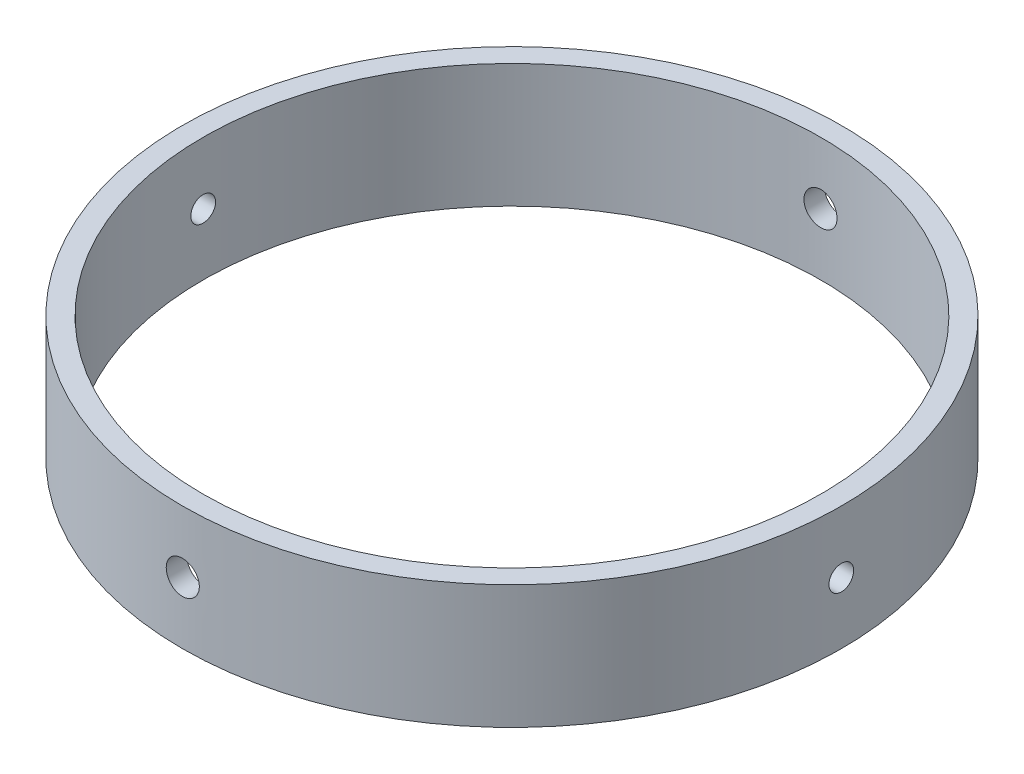
from build123d import *

# Parameters (mm, degrees)
SKETCH1_R                       = 50.8
SKETCH1_R_2                     = 47.625
BOSS_EXTRUDE1_DEPTH             = 19.05
SKETCH5_W                       = 2.5527
SKETCH5_H                       = 82.55
TAP_DRILL_FOR_1_4_20_TAP2_D     = 5.1054
TAP_DRILL_FOR_1_4_20_TAP2_DEPTH = 82.55
SKETCH10_R                      = 1.905
CUT_EXTRUDE3_DEPTH              = 83.5500001
CUT_EXTRUDE3_DEPTH_BACK         = 20.0500001


with BuildPart() as part:
    # Sketch1 → Boss-Extrude1 (new body)
    with BuildSketch(Plane(origin=(0, 0, 0), x_dir=(1, 0, 0), z_dir=(0, 1, 0))):
        Circle(SKETCH1_R)
        Circle(SKETCH1_R_2, mode=Mode.SUBTRACT)
    extrude(amount=BOSS_EXTRUDE1_DEPTH)

    # Sketch5 → Tap Drill for 1/4-20 Tap1 (revolve, cut)
    with BuildSketch(Plane(origin=(0, 9.525, 31.75), x_dir=(0, -1, 0), z_dir=(1, 0, 0))):
        with Locations((1.27635, 41.275)):
            Rectangle(SKETCH5_W, SKETCH5_H)
    revolve(axis=Axis((0, 9.525, 38.1), (0, 0, -1)), mode=Mode.SUBTRACT)

    # Tap Drill for 1/4-20 Tap2
    with Locations(Plane(origin=(0, 0, -31.75), x_dir=(1, 0, 0), z_dir=(0, 0, -1))):
        with Locations((0, -9.525)):
            Hole(TAP_DRILL_FOR_1_4_20_TAP2_D / 2, depth=TAP_DRILL_FOR_1_4_20_TAP2_DEPTH)

    # Sketch10 → Cut-Extrude3 (cut, two sides)
    with BuildSketch(Plane(origin=(-31.75, 0, 0), x_dir=(0, 0, -1), z_dir=(1, 0, 0))) as cut_extrude3_sk:
        with Locations((0, 9.487883811)):
            Circle(SKETCH10_R)
    extrude(amount=CUT_EXTRUDE3_DEPTH, mode=Mode.SUBTRACT)
    extrude(cut_extrude3_sk.sketch, amount=-CUT_EXTRUDE3_DEPTH_BACK, mode=Mode.SUBTRACT)


solid = part.part
